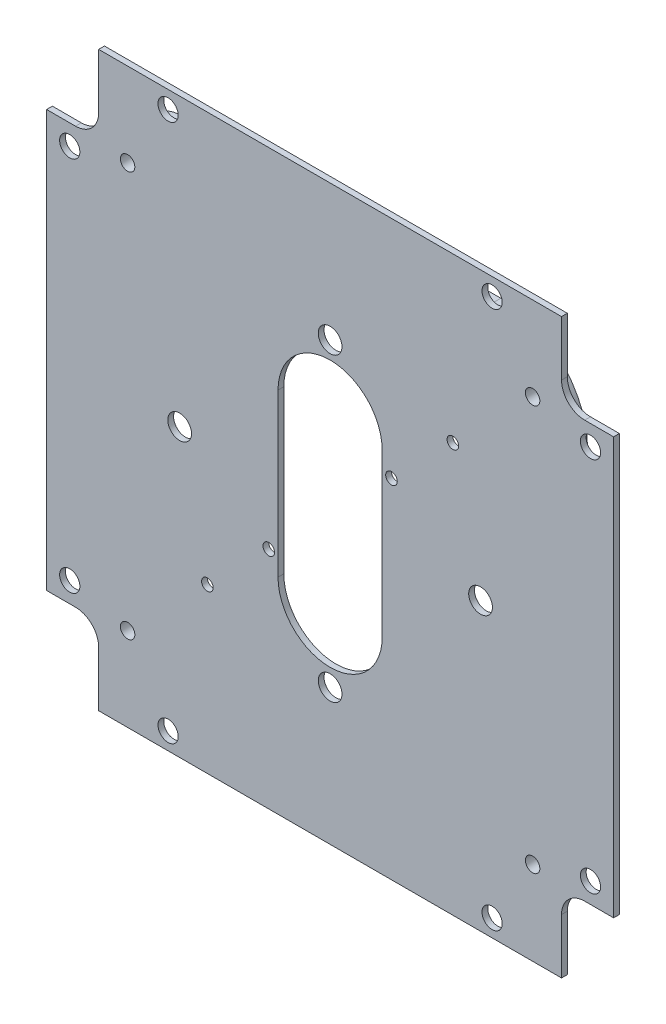
from build123d import *

# Parameters (mm, degrees)
SKETCH1_W                      = 98
SKETCH1_H                      = 99
MAIN_BODY_DEPTH                = 1
SKETCH2_R                      = 1.75
FRONTBACKBOLTHOLES_DEPTH       = 2
SKETCH3_R                      = 1.75
SIDEBOLTHOLES_DEPTH            = 2
SKETCH7_W                      = 9
SKETCH7_H                      = 13.5
CUT_EXTRUDE3_DEPTH             = 2
FILLET1_R                      = 4
BOSS_EXTRUDE4_DEPTH            = 2
CAMERAVIEWHOLE_DEPTH           = 4
M3X0_5_TAPPED_HOLE1_D          = 2.5
M3X0_5_TAPPED_HOLE1_DEPTH      = 7.5
M3X0_5_TAPPED_HOLE1_TIP        = 0.751075774
SKETCH16_R                     = 1
WIREPASSTHROUGHS_DEPTH         = 4
SKETCH17_R                     = 2.05
NOTSUREIFNEEDPASSTHROUGH_DEPTH = 4


with BuildPart() as part:
    # Sketch1 → Main Body (new body)
    with BuildSketch(Plane.XY):
        with Locations((49, 49.5)):
            Rectangle(SKETCH1_W, SKETCH1_H)
    extrude(amount=MAIN_BODY_DEPTH)

    # Sketch2 → FrontBackBoltHoles (cut, through all)
    with BuildSketch(Plane.XY.offset(1)):
        with Locations((4, 82)):
            Circle(SKETCH2_R)
        with Locations((94, 82)):
            Circle(SKETCH2_R)
        with Locations((94, 17)):
            Circle(SKETCH2_R)
        with Locations((4, 17)):
            Circle(SKETCH2_R)
    extrude(amount=-FRONTBACKBOLTHOLES_DEPTH, mode=Mode.SUBTRACT)

    # Sketch3 → SideBoltHoles (cut, through all)
    with BuildSketch(Plane.XY.offset(1)):
        with Locations((21, 96)):
            Circle(SKETCH3_R)
        with Locations((77, 96)):
            Circle(SKETCH3_R)
        with Locations((77, 3)):
            Circle(SKETCH3_R)
        with Locations((21, 3)):
            Circle(SKETCH3_R)
    extrude(amount=-SIDEBOLTHOLES_DEPTH, mode=Mode.SUBTRACT)

    # Sketch7 → Cut-Extrude3 (cut, through all)
    with BuildSketch(Plane.XY.offset(1)):
        with Locations((4.5, 92.25)):
            Rectangle(SKETCH7_W, SKETCH7_H)
        with Locations((93.5, 92.25)):
            Rectangle(SKETCH7_W, SKETCH7_H)
        with Locations((93.5, 6.75)):
            Rectangle(SKETCH7_W, SKETCH7_H)
        with Locations((4.5, 6.75)):
            Rectangle(SKETCH7_W, SKETCH7_H)
    extrude(amount=-CUT_EXTRUDE3_DEPTH, mode=Mode.SUBTRACT)

    # Fillet1
    fillet1_edges = [part.edges().sort_by_distance(p)[0] for p in [
        (89, 85.5, 0.5),
        (9, 13.5, 0.5),
        (89, 13.5, 0.5),
        (9, 85.5, 0.5),
    ]]
    fillet(fillet1_edges, radius=FILLET1_R)

    # Sketch15 → Boss-Extrude4 (add)
    with BuildSketch(Plane(origin=(0, 0, 0), x_dir=(-1, 0, 0), z_dir=(0, 0, -1))):
        with BuildLine():
            Line((-22.5, 93.5), (-75.5, 93.5))
            ThreePointArc((-75.5, 93.5), (-86.106601718, 89.106601718), (-90.5, 78.5))
            Line((-90.5, 78.5), (-90.5, 20.5))
            ThreePointArc((-90.5, 20.5), (-86.106601718, 9.893398282), (-75.5, 5.5))
            Line((-75.5, 5.5), (-22.5, 5.5))
            ThreePointArc((-22.5, 5.5), (-11.893398282, 9.893398282), (-7.5, 20.5))
            Line((-7.5, 20.5), (-7.5, 78.5))
            ThreePointArc((-7.5, 78.5), (-11.893398282, 89.106601718), (-22.5, 93.5))
        make_face()
        with BuildLine():
            Line((-35.5, 90.5), (-62.5, 90.5))
            ThreePointArc((-62.5, 90.5), (-80.17766953, 83.17766953), (-87.5, 65.5))
            Line((-87.5, 65.5), (-87.5, 33.5))
            ThreePointArc((-87.5, 33.5), (-80.17766953, 15.82233047), (-62.5, 8.5))
            Line((-62.5, 8.5), (-35.5, 8.5))
            ThreePointArc((-35.5, 8.5), (-17.82233047, 15.82233047), (-10.5, 33.5))
            Line((-10.5, 33.5), (-10.5, 65.5))
            ThreePointArc((-10.5, 65.5), (-17.82233047, 83.17766953), (-35.5, 90.5))
        make_face(mode=Mode.SUBTRACT)
    extrude(amount=BOSS_EXTRUDE4_DEPTH)

    # Sketch10 → CameraViewHole (cut, through all)
    with BuildSketch(Plane.XY.offset(1)):
        with BuildLine():
            Line((40, 35.5), (40, 63.5))
            ThreePointArc((40, 63.5), (49, 72.5), (58, 63.5))
            Line((58, 63.5), (58, 35.5))
            ThreePointArc((58, 35.5), (49, 26.5), (40, 35.5))
        make_face()
    extrude(amount=-CAMERAVIEWHOLE_DEPTH, mode=Mode.SUBTRACT)

    # M3x0.5 Tapped Hole1
    with Locations(Plane.XY.offset(1)):
        with Locations((84, 14.5), (14, 14.5), (14, 84.5), (84, 84.5)):
            Hole(M3X0_5_TAPPED_HOLE1_D / 2, depth=M3X0_5_TAPPED_HOLE1_DEPTH)
            with Locations((0, 0, -(M3X0_5_TAPPED_HOLE1_DEPTH + M3X0_5_TAPPED_HOLE1_TIP / 2))):  # 118° drill point
                Cone(0, M3X0_5_TAPPED_HOLE1_D / 2, M3X0_5_TAPPED_HOLE1_TIP, mode=Mode.SUBTRACT)

    # Sketch16 → WirePassthroughs (cut, through all)
    with BuildSketch(Plane.XY.offset(1)):
        with Locations((27.787, 28.287)):
            Circle(SKETCH16_R)
        with Locations((38.393, 38.893)):
            Circle(SKETCH16_R)
        with Locations((59.607, 60.107)):
            Circle(SKETCH16_R)
        with Locations((70.213, 70.713)):
            Circle(SKETCH16_R)
    extrude(amount=-WIREPASSTHROUGHS_DEPTH, mode=Mode.SUBTRACT)

    # Sketch17 → NotSureIfNeedPassthrough (cut, through all)
    with BuildSketch(Plane.XY.offset(1)):
        with Locations((49, 23.5)):
            Circle(SKETCH17_R)
        with Locations((23, 49.5)):
            Circle(SKETCH17_R)
        with Locations((49, 75.5)):
            Circle(SKETCH17_R)
        with Locations((75, 49.5)):
            Circle(SKETCH17_R)
    extrude(amount=-NOTSUREIFNEEDPASSTHROUGH_DEPTH, mode=Mode.SUBTRACT)


solid = part.part
